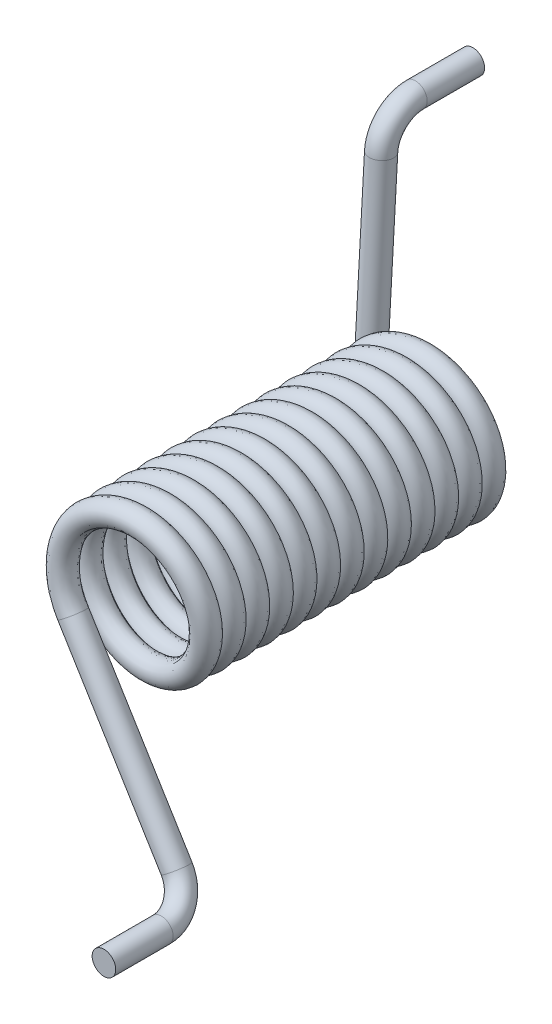
from build123d import *

# Parameters (mm, degrees)
SKIZZE2_R = 2.745


with BuildPart() as part:
    # Austragung1: sweep along a curve in space
    with BuildLine() as austragung1_path:
        Line((-15.25, 53, -10.596174722), (-15.25, 53, -23.975))
        ThreePointArc((-15.25, 45.458446529, -2.60932135), (-15.25, 50.81668171, -5.103796923), (-15.25, 53, -10.596174722))
        Line((-15.25, 0, 0), (-15.25, 45.458446529, -2.60932135))
        add(Edge.make_bspline(
            [(-15.25, 0, 0), (-15.25, -1.841180339, 0.105684015), (-14.568244065, -5.55817401, 0.319076541), (-11.634495176, -10.377292168, 0.637537943), (-7.174491097, -13.842376092, 0.956435403), (-1.773311308, -15.489611922, 1.275216021), (3.860497878, -15.105388261, 1.594027947), (8.987872978, -12.739444722, 1.912831484), (12.936186369, -8.702332326, 2.231637269), (15.187484008, -3.523606398, 2.550442451), (15.446432523, 2.117356271, 2.869247795), (13.67906211, 7.480557204, 3.188053095), (10.117222817, 11.862431372, 3.506858408), (5.228169614, 14.688148908, 3.825663717), (-0.346733802, 15.587021891, 4.144469027), (-5.876151423, 14.441132928, 4.463274336), (-10.634714231, 11.400803876, 4.782079646), (-13.998176733, 6.864876105, 5.100884956), (-15.525307744, 1.428389038, 5.419690265), (-15.01577269, -4.195479272, 5.738495575), (-12.536414223, -9.268969426, 6.057300885), (-8.412483562, -13.126522621, 6.376106195), (-3.184972858, -15.262091065, 6.694911504), (2.460354114, -15.395523162, 7.013716814), (7.782922928, -13.509314805, 7.332522124), (12.084499741, -9.850905633, 7.651327434), (14.800788138, -4.900219005, 7.970132743), (15.575455574, 0.69329609, 8.288938053), (14.306878371, 6.195862093, 8.607743363), (11.161473078, 10.885632481, 8.926548673), (6.551865347, 14.147386199, 9.245353982), (1.082760205, 15.553234587, 9.564159292), (-4.52838534, 14.918753366, 9.882964602), (-9.545480905, 12.327176079, 10.201769912), (-13.310365734, 8.118475215, 10.520575221), (-15.329148609, 2.844763386, 10.839380531), (-15.336998284, -2.8021348, 11.158185841), (-13.33288501, -8.081438801, 11.47699115), (-9.579715622, -12.300590409, 11.79579646), (-4.569844463, -14.906106043, 12.11460177), (1.039515433, -15.556184733, 12.43340708), (6.512507932, -14.165546803, 12.752212389), (11.131166068, -10.91662117, 13.071017699), (14.289597549, -6.235613658, 13.389823009), (15.573467901, -0.736595776, 13.708628319), (14.814354364, 4.859051406, 14.027433628), (12.111840201, 9.817270636, 14.346238938), (7.820451, 13.487624771, 14.665044248), (2.50314673, 15.388623468, 14.983849558), (-3.142529389, 15.270886839, 15.302654867), (-8.375957127, 13.149859999, 15.621460177), (-12.510596492, 9.303786928, 15.940265487), (-15.004050526, 4.237209412, 16.259070796), (-15.529218904, -1.385220571, 16.577876106), (-14.017208136, -6.825932307, 16.896681416), (-10.666369269, -11.371193535, 17.215486726), (-5.916277474, -14.424740436, 17.534292035), (-0.390066985, -15.585997676, 17.853097345), (5.187313903, -14.702627325, 18.171902655), (10.084204178, -11.890513105, 18.490707965), (13.658212047, -7.518558337, 18.809513274), (15.440486224, -2.160291872, 19.128318584), (15.197221529, 3.4813695, 19.447123894), (12.960330307, 8.66633222, 19.765929204), (9.023256044, 12.71441411, 20.084734513), (3.902478392, 15.094573137, 20.403539823), (-1.7302405, 15.494571424, 20.722345133), (-7.13598018, 13.861935747, 21.041150442), (-11.605596151, 10.410841165, 21.359955752), (-14.552748012, 5.594014756, 21.678761062), (-15.590817714, 0.043345243, 21.997566372), (-14.583627515, -5.513010456, 22.316371681), (-11.663304273, -10.346149488, 22.635176991), (-7.21294656, -13.822043182, 22.953982301), (-1.816368409, -15.484711221, 23.272787611), (3.818487524, -15.116038794, 23.59159292), (8.952420443, -12.764389684, 23.91039823), (12.911942443, -8.738261734, 24.22920354), (15.177629099, -3.565816981, 24.54800885), (15.452259432, 2.074404551, 24.866814159), (13.699806442, 7.442498185, 25.185619469), (10.150163256, 11.834257969, 25.504424779), (5.268984915, 14.673556957, 25.823230088), (-0.30339794, 15.587925631, 26.142035398), (-5.835979954, 14.4574138, 26.460840708), (-10.602976994, 11.430326096, 26.779646018), (-13.979037134, 6.903766842, 27.098451327), (-15.521276584, 1.471546465, 27.417256637), (-15.027378791, -4.153716704, 27.736061947), (-12.562135056, -9.23408028, 28.054867257), (-8.448944975, -13.103083782, 28.373672566), (-3.22739171, -15.253177326, 28.692477876), (2.417542482, -15.402303858, 29.011283186), (7.7453347, -13.53090042, 29.330088496), (12.057065877, -9.884464489, 29.648893805), (14.787107511, -4.941348728, 29.967699115), (15.577322858, 0.649991044, 30.286504425), (14.32404861, 6.156062639, 30.605309735), (11.191693818, 10.854559654, 30.924115044), (6.591172122, 14.129116245, 31.242920354), (1.125996609, 15.550164225, 31.561725664), (-4.486891214, 14.931285377, 31.880530973), (-9.511172408, 12.353666469, 32.199336283), (-13.287743578, 8.155448878, 32.518141593), (-15.32118045, 2.887369984, 32.836946903), (-15.344729414, -2.759484556, 33.155752212), (-13.355301232, -8.044339923, 33.474557522), (-9.613876294, -12.273909663, 33.793362832), (-4.611268265, -14.893343506, 34.112168142), (0.996262625, -15.55901464, 34.430973451), (6.473100178, -14.183597917, 34.749778761), (11.10077302, -10.94752548, 35.068584071), (14.272206277, -6.275317026, 35.387389381), (15.571359855, -0.77988977, 35.70619469), (14.827806086, 4.817846249, 36.025), (12.139087043, 9.783559759, 36.34380531), (7.857918624, 13.465830486, 36.662610619), (2.545919998, 15.38160483, 36.981415929), (-3.100061629, 15.279564578, 37.300221239), (-8.339365951, 13.173095738, 37.619026549), (-12.484682062, 9.338532519, 37.937831858), (-14.992212391, 4.278906802, 38.256637168), (-15.533010033, -1.342041397, 38.575442478), (-14.036131196, -6.786935748, 38.894247788), (-10.697941863, -11.341495302, 39.213053097), (-5.956357795, -14.40823645, 39.531858407), (-0.433397152, -15.584852989, 39.850663717), (5.146418098, -14.716992103, 40.169469027), (10.051107595, -11.918502923, 40.488274336), (13.637256416, -7.556501389, 40.807079646), (15.434420579, -2.203210652, 41.125884956), (15.206841585, 3.439105233, 41.444690265), (12.984374069, 8.630266846, 41.763495575), (9.058569365, 12.689278815, 42.082300885), (3.944428743, 15.08366526, 42.401106195), (-1.687156318, 15.4993219, 42.719911504), (-7.097414107, 13.881721391, 43.038716814), (-11.576607424, 10.443066425, 43.357522124), (-14.537139476, 5.634452205, 43.676327434), (-15.590636953, 0.086690151, 43.995132743), (-14.598898244, -5.472444231, 44.313938053), (-11.692023221, -10.313683571, 44.632743363), (-7.251346271, -13.801936569, 44.951548673), (-1.859411471, -15.47960157, 45.270353982), (3.776447656, -15.126596408, 45.589159292), (8.916898711, -12.789229577, 45.907964602), (12.887598717, -8.774125319, 46.226769912), (15.167656876, -3.607999542, 46.545575221), (15.457966905, 2.031436674, 46.864380531), (13.720444884, 7.404381674, 47.183185841), (10.183025241, 11.805993085, 47.50199115), (5.309759489, 14.658851591, 47.82079646), (-0.260059732, 15.588708886, 48.13960177), (-5.795763376, 14.473582925, 48.45840708), (-10.571157803, 11.459759967, 48.777212389), (-13.959789485, 6.942604218, 49.096017699), (-15.517125455, 1.514692517, 49.414823009), (-15.038868741, -4.11192203, 49.733628319), (-12.587758792, -9.199119762, 50.052433628), (-8.485341082, -13.079543666, 50.371238938), (-3.269785616, -15.24414569, 50.690044248), (2.374712163, -15.408965505, 51.008849558), (7.707686605, -13.552381451, 51.327654867), (12.029538819, -9.917946944, 51.646460177), (14.773312589, -4.982440259, 51.965265487), (15.579069741, 0.606680975, 52.284070796), (14.341108134, 6.116215602, 52.602876106), (11.221828053, 10.823402928, 52.921681416), (6.63042795, 14.110737082, 53.240486726), (1.169224309, 15.54697367, 53.559292035), (-4.445362409, 14.943701979, 53.878097345), (-9.476790395, 12.380061373, 54.196902655), (-13.265018716, 8.192359505, 54.515707965), (-15.313093868, 2.929954264, 54.834513274), (-15.352341939, -2.716812982, 55.153318584), (-13.377614226, -8.007178868, 55.472123894), (-9.647962657, -12.247134047, 55.790929204), (-4.652656425, -14.880465852, 56.109734513), (0.953002117, -15.561724286, 56.428539823), (6.433642392, -14.201539401, 56.747345133), (11.070294171, -10.978345174, 57.066150442), (14.254704691, -6.314971889, 57.384955752), (15.569131453, -0.823177735, 57.703761062), (14.841143198, 4.776603854, 58.022566372), (12.166240059, 9.74977326, 58.341371681), (7.895325512, 13.44393212, 58.660176991), (2.588673587, 15.374467303, 58.978982301), (-3.057569909, 15.288124216, 59.297787611), (-8.302710317, 13.196229658, 59.61659292), (-12.458671134, 9.373205928, 59.93539823), (-14.980258376, 4.320571118, 60.25420354), (-15.536681102, -1.29885185, 60.57300885), (-14.054945765, -6.747886732, 60.891814159), (-10.729431769, -11.311709407, 61.210619469), (-5.996392078, -14.391621098, 61.529424779), (-0.47672397, -15.583587843, 61.848230088), (5.105482515, -14.731243128, 62.167035398), (10.017933323, -11.946400618, 62.485840708), (13.616195377, -7.594386035, 62.804646018), (15.428235637, -2.246112403, 63.123451327), (15.216344102, 3.396814384, 63.442256637), (13.008317471, 8.594134765, 63.761061947), (9.09381267, 12.664045441, 64.079867257), (3.986348606, 15.072640797, 64.398672566), (-1.644059096, 15.503952576, 64.717477876), (-7.058793175, 13.901399739, 65.036283186), (-11.547529216, 10.475210967, 65.355088496), (-14.521418577, 5.674846104, 65.673893805), (-15.590335688, 0.130034389, 65.992699115), (-14.614056132, -5.431835708, 66.311504425), (-11.720651797, -10.281137936, 66.630309735), (-7.289689934, -13.781723276, 66.949115044), (-1.902440161, -15.474372272, 67.267920354), (3.734378599, -15.137037104, 67.586725664), (8.881308057, -12.813970617, 67.905530973), (12.863155379, -8.809921087, 68.224336283), (15.157567411, -3.650154209, 68.543141592), (15.463554917, 1.988453068, 68.861946905), (13.740977204, 7.366208031, 69.180752205), (10.215808789, 11.777636577, 69.499557549), (5.350492013, 14.644034311, 69.818362731), (-0.216715747, 15.589366465, 70.137168516), (-5.75551606, 14.489659529, 70.455972053), (-10.539204436, 11.489033047, 70.774783979), (-13.940629747, 6.981657442, 71.093564597), (-15.512123613, 1.556821037, 71.412462057), (-15.05296974, -4.066341782, 71.730923459), (-13.419727814, -7.474178914, 71.944315985), (-12.337509164, -8.963725097, 72.05)],
            knots=[0, 0, 0, 0, 0.004424779, 0.008849558, 0.013274336, 0.017699115, 0.022123894, 0.026548673, 0.030973451, 0.03539823, 0.039823009, 0.044247788, 0.048672566, 0.053097345, 0.057522124, 0.061946903, 0.066371681, 0.07079646, 0.075221239, 0.079646018, 0.084070796, 0.088495575, 0.092920354, 0.097345133, 0.101769912, 0.10619469, 0.110619469, 0.115044248, 0.119469027, 0.123893805, 0.128318584, 0.132743363, 0.137168142, 0.14159292, 0.146017699, 0.150442478, 0.154867257, 0.159292035, 0.163716814, 0.168141593, 0.172566372, 0.17699115, 0.181415929, 0.185840708, 0.190265487, 0.194690265, 0.199115044, 0.203539823, 0.207964602, 0.212389381, 0.216814159, 0.221238938, 0.225663717, 0.230088496, 0.234513274, 0.238938053, 0.243362832, 0.247787611, 0.252212389, 0.256637168, 0.261061947, 0.265486726, 0.269911504, 0.274336283, 0.278761062, 0.283185841, 0.287610619, 0.292035398, 0.296460177, 0.300884956, 0.305309735, 0.309734513, 0.314159292, 0.318584071, 0.32300885, 0.327433628, 0.331858407, 0.336283186, 0.340707965, 0.345132743, 0.349557522, 0.353982301, 0.35840708, 0.362831858, 0.367256637, 0.371681416, 0.376106195, 0.380530973, 0.384955752, 0.389380531, 0.39380531, 0.398230088, 0.402654867, 0.407079646, 0.411504425, 0.415929204, 0.420353982, 0.424778761, 0.42920354, 0.433628319, 0.438053097, 0.442477876, 0.446902655, 0.451327434, 0.455752212, 0.460176991, 0.46460177, 0.469026549, 0.473451327, 0.477876106, 0.482300885, 0.486725664, 0.491150442, 0.495575221, 0.5, 0.504424779, 0.508849558, 0.513274336, 0.517699115, 0.522123894, 0.526548673, 0.530973451, 0.53539823, 0.539823009, 0.544247788, 0.548672566, 0.553097345, 0.557522124, 0.561946903, 0.566371681, 0.57079646, 0.575221239, 0.579646018, 0.584070796, 0.588495575, 0.592920354, 0.597345133, 0.601769912, 0.60619469, 0.610619469, 0.615044248, 0.619469027, 0.623893805, 0.628318584, 0.632743363, 0.637168142, 0.64159292, 0.646017699, 0.650442478, 0.654867257, 0.659292035, 0.663716814, 0.668141593, 0.672566372, 0.67699115, 0.681415929, 0.685840708, 0.690265487, 0.694690265, 0.699115044, 0.703539823, 0.707964602, 0.712389381, 0.716814159, 0.721238938, 0.725663717, 0.730088496, 0.734513274, 0.738938053, 0.743362832, 0.747787611, 0.752212389, 0.756637168, 0.761061947, 0.765486726, 0.769911504, 0.774336283, 0.778761062, 0.783185841, 0.787610619, 0.792035398, 0.796460177, 0.800884956, 0.805309735, 0.809734513, 0.814159292, 0.818584071, 0.82300885, 0.827433628, 0.831858407, 0.836283186, 0.840707965, 0.845132743, 0.849557522, 0.853982301, 0.85840708, 0.862831858, 0.867256637, 0.871681416, 0.876106195, 0.880530973, 0.884955752, 0.889380531, 0.89380531, 0.898230088, 0.902654867, 0.907079646, 0.911504425, 0.915929204, 0.920353982, 0.924778761, 0.92920354, 0.933628319, 0.938053097, 0.942477876, 0.946902655, 0.951327434, 0.955752212, 0.960176991, 0.96460177, 0.969026549, 0.973451327, 0.977876106, 0.982300885, 0.986725664, 0.991150442, 0.995575221, 1, 1, 1, 1], degree=3))
        Line((-12.337509164, -8.963725097, 72.05), (14.382295298, -45.740380877, 74.65932135))
        ThreePointArc((14.382295298, -45.740380877, 74.65932135), (17.531786915, -50.075284199, 77.153796923), (18.815109207, -51.841625799, 82.646174722))
        Line((18.815109207, -51.841625799, 82.646174722), (18.815109207, -51.841625799, 96.025))
    # Skizze2 → Austragung1 (sweep)
    with BuildSketch(Plane(origin=(-15.25, 53, -23.975), x_dir=(-1, 0, 0), z_dir=(0, 0, -1))):
        Circle(SKIZZE2_R)
    sweep(path=austragung1_path.line, is_frenet=True)


solid = part.part
